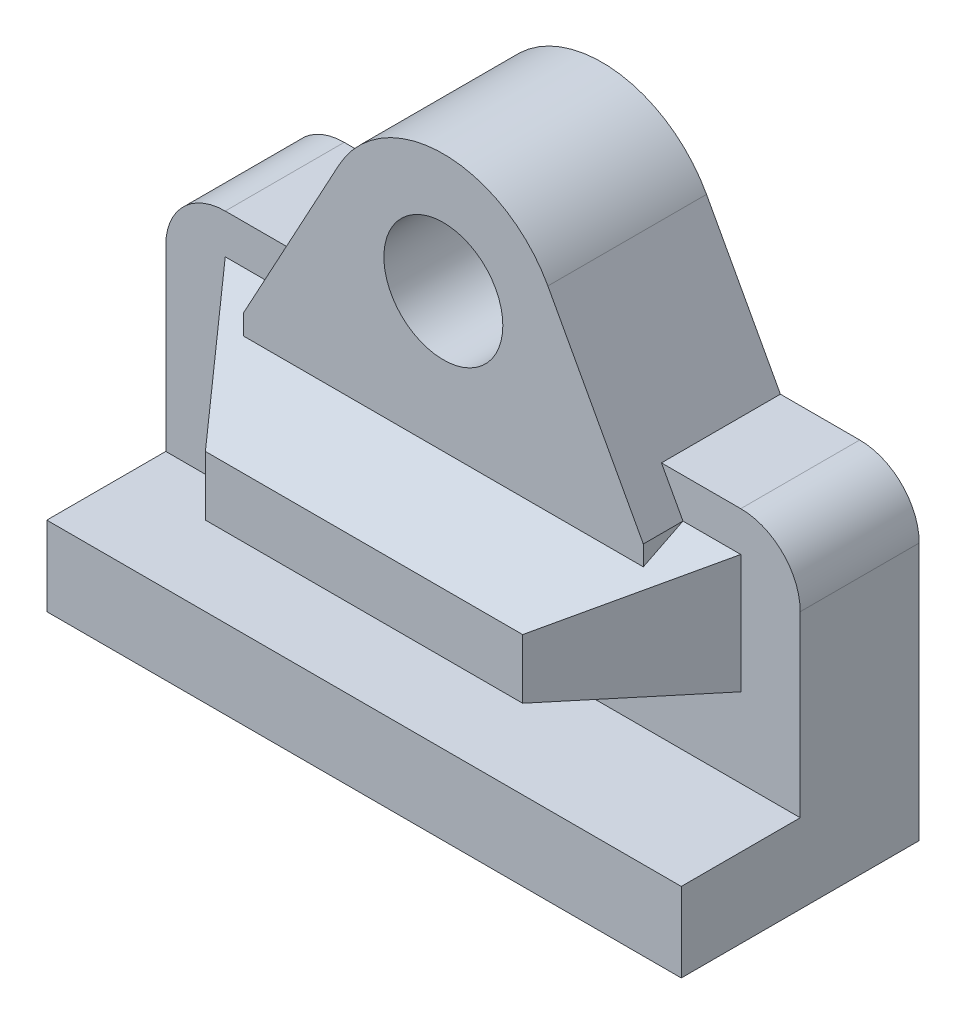
from build123d import *

# Parameters (mm, degrees)
SKETCH1_R           = 9.525
BOSS_EXTRUDE1_DEPTH = 19.05
SKETCH1_3_W         = 101.6
SKETCH1_3_H         = 12.7
BOSS_EXTRUDE2_DEPTH = 38.1
SKETCH6_R           = 9.525
BOSS_EXTRUDE6_DEPTH = 6.35
BOSS_EXTRUDE7_REACH = 119.26
SKETCH7_W           = 64.047051266
SKETCH7_H           = 6.35


with BuildPart() as part:
    # Sketch1 → Boss-Extrude1 (new body)
    with BuildSketch(Plane.XY):
        with BuildLine():
            Line((0, 41.275), (0, 12.7))
            Line((0, 12.7), (101.6, 12.7))
            Line((101.6, 12.7), (101.6, 41.275))
            ThreePointArc((101.6, 41.275), (98.810192091, 48.010192091), (92.075, 50.8))
            Line((92.075, 50.8), (79.375, 50.8))
            Line((79.375, 50.8), (67.540629127, 72.591415535))
            ThreePointArc((67.540629127, 72.591415535), (50.8, 82.55), (34.059370873, 72.591415535))
            Line((34.059370873, 72.591415535), (22.225, 50.8))
            Line((22.225, 50.8), (9.525, 50.8))
            ThreePointArc((9.525, 50.8), (2.789807909, 48.010192091), (0, 41.275))
        make_face()
        with Locations((50.8, 63.5)):
            Circle(SKETCH1_R, mode=Mode.SUBTRACT)
    extrude(amount=BOSS_EXTRUDE1_DEPTH)

    # Sketch1_3 → Boss-Extrude2 (add)
    with BuildSketch(Plane.XY):
        with Locations((50.8, 6.35)):
            Rectangle(SKETCH1_3_W, SKETCH1_3_H)
    extrude(amount=BOSS_EXTRUDE2_DEPTH)

    # Sketch5 → Loft1 section 0
    with BuildSketch(Plane.XY.offset(19.05)):
        with BuildLine():
            Line((9.525, 25.4), (92.075, 25.4))
            Line((92.075, 25.4), (92.075, 44.45))
            Line((92.075, 44.45), (9.525, 44.45))
            Line((9.525, 44.45), (9.525, 25.4))
        make_face()
    # Sketch2 → Loft1 section 1
    with BuildSketch(Plane.XY.offset(38.1)):
        with BuildLine():
            Line((25.4, 25.4), (76.2, 25.4))
            Line((76.2, 25.4), (76.2, 34.925))
            Line((76.2, 34.925), (25.4, 34.925))
            Line((25.4, 34.925), (25.4, 25.4))
        make_face()
    loft()

    # Sketch6 → Boss-Extrude6 (add)
    with BuildSketch(Plane.XY.offset(19.05)):
        with BuildLine():
            Line((34.059370873, 72.591415535), (18.776474367, 44.45))
            Line((18.776474367, 44.45), (82.823525633, 44.45))
            Line((82.823525633, 44.45), (67.540629127, 72.591415535))
            ThreePointArc((67.540629127, 72.591415535), (50.8, 82.55), (34.059370873, 72.591415535))
        make_face()
        with Locations((50.8, 63.5)):
            Circle(SKETCH6_R, mode=Mode.SUBTRACT)
    extrude(amount=BOSS_EXTRUDE6_DEPTH)

    # Sketch7 → Boss-Extrude7 (add, up to next)
    with BuildSketch(Plane.XZ.offset(-44.45), mode=Mode.PRIVATE) as boss_extrude7_sk1:
        with Locations((50.8, 22.225)):
            Rectangle(SKETCH7_W, SKETCH7_H)
    boss_extrude7_tool1 = extrude(boss_extrude7_sk1.sketch, amount=BOSS_EXTRUDE7_REACH, mode=Mode.PRIVATE) - part.part
    add(boss_extrude7_tool1.solids().sort_by_distance((50.8, 44.45, 22.225))[0])


solid = part.part
